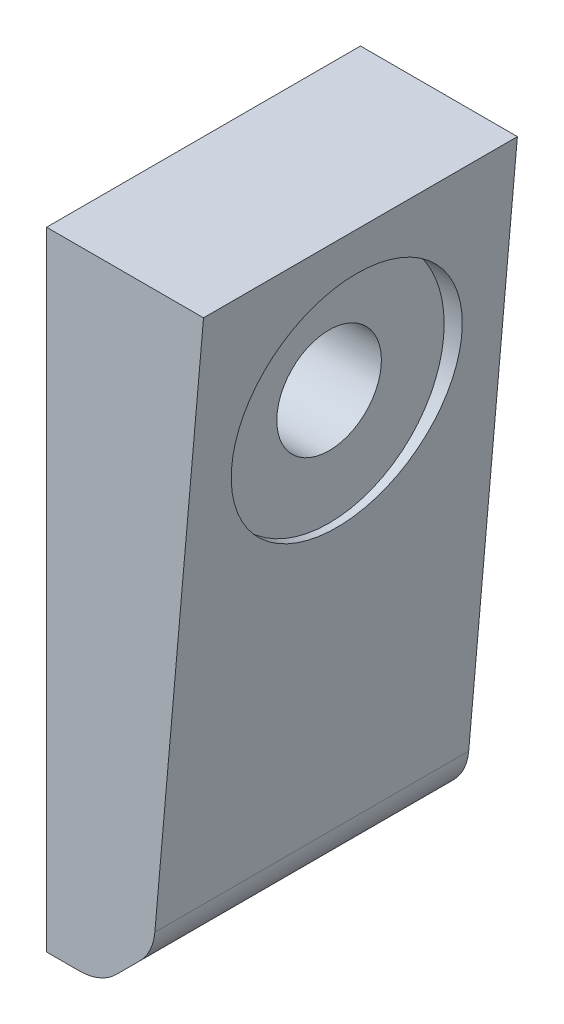
from build123d import *

# Parameters (mm, degrees)
EXTRUDE_1_DEPTH     = 30
SKETCH_3_R          = 5
CUT_EXTRUDE_2_DEPTH = 21
CUT_EXTRUDE_START   = -15
SKETCH_5_R          = 11
CUT_EXTRUDE_3_DEPTH = 3


with BuildPart() as part:
    # Эскиз1 → Бобышка-Вытянуть1 (new body)
    with BuildSketch(Plane.XY):
        with BuildLine():
            Line((0, 0), (0, -60))
            Line((0, -60), (3.117055694, -60))
            ThreePointArc((3.117055694, -60), (5.030472856, -59.619397663), (6.6525896, -58.535533906))
            Line((6.6525896, -58.535533906), (8.901294402, -56.286829104))
            ThreePointArc((8.901294402, -56.286829104), (9.897299431, -54.864386507), (10.346733987, -53.187073912))
            Line((10.346733987, -53.187073912), (15, 0))
            Line((15, 0), (0, 0))
        make_face()
    extrude(amount=EXTRUDE_1_DEPTH)

    # Эскиз3 → Вырез-Вытянуть2 (cut)
    with BuildSketch(Plane.ZY):
        with Locations((15, -15)):
            Circle(SKETCH_3_R)
    extrude(amount=-CUT_EXTRUDE_2_DEPTH, mode=Mode.SUBTRACT)

    # Эскиз5 → Вырез-Вытянуть3 (cut)
    with BuildSketch(Plane.ZY.offset(CUT_EXTRUDE_START)):
        with Locations((15, -15)):
            Circle(SKETCH_5_R)
    extrude(amount=CUT_EXTRUDE_3_DEPTH, mode=Mode.SUBTRACT)


solid = part.part
